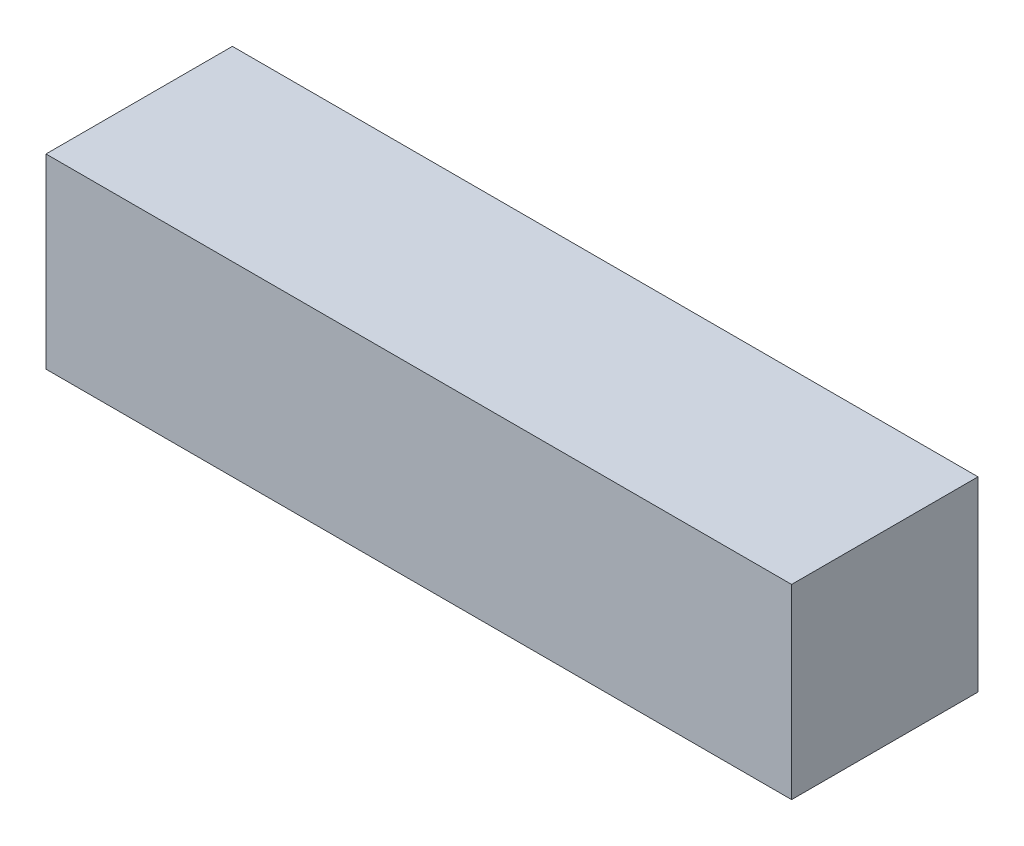
from build123d import *

# Parameters (mm, degrees)
SKETCH1_W           = 40
SKETCH1_H           = 10
BOSS_EXTRUDE1_DEPTH = 10


with BuildPart() as part:
    # Sketch1 → Boss-Extrude1 (new body)
    with BuildSketch(Plane(origin=(0, 0, 0), x_dir=(1, 0, 0), z_dir=(0, 1, 0))):
        Rectangle(SKETCH1_W, SKETCH1_H)
    extrude(amount=BOSS_EXTRUDE1_DEPTH)


solid = part.part
